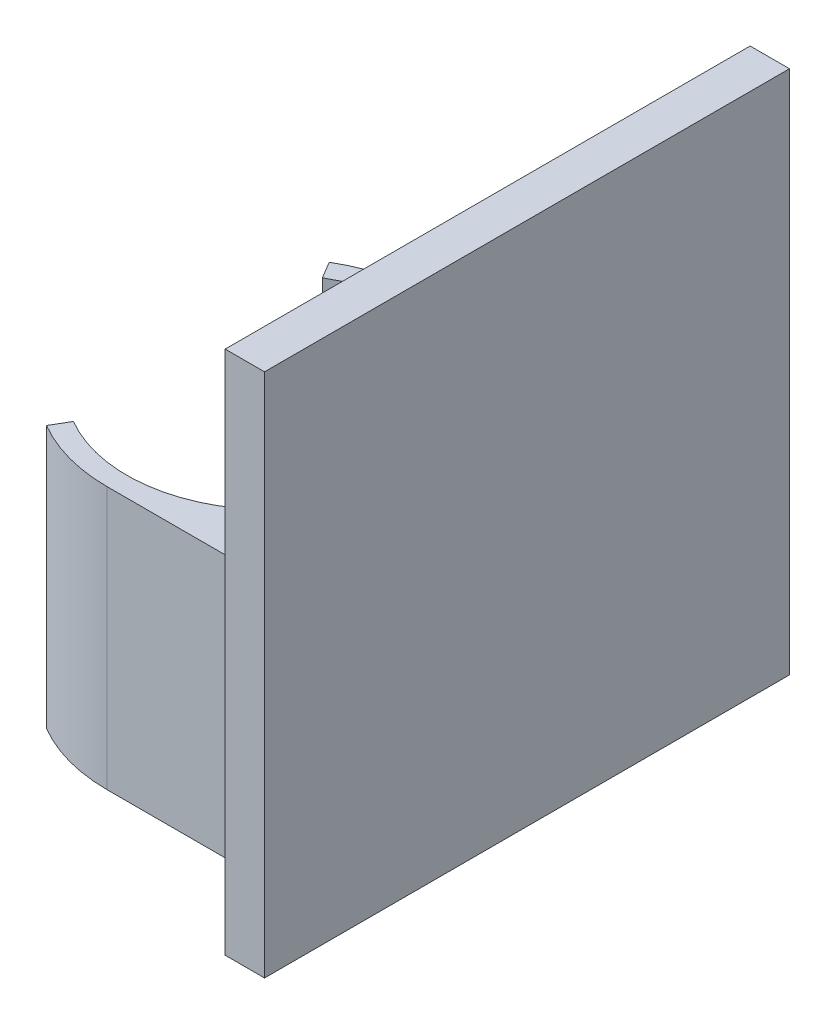
from build123d import *

# Parameters (mm, degrees)
SKETCH23_W          = 25
SKETCH23_H          = 25
BOSS_EXTRUDE6_DEPTH = 20
SKETCH24_R          = 11
CUT_EXTRUDE7_DEPTH  = 21
CUT_EXTRUDE8_DEPTH  = 21
SKETCH26_W          = 40
SKETCH26_H          = 40
BOSS_EXTRUDE7_DEPTH = 3


with BuildPart() as part:
    # Sketch23 → Boss-Extrude6 (new body)
    with BuildSketch(Plane(origin=(0, 0, 0), x_dir=(1, 0, 0), z_dir=(0, 1, 0))):
        Rectangle(SKETCH23_W, SKETCH23_H)
    extrude(amount=BOSS_EXTRUDE6_DEPTH)

    # Sketch24 → Cut-Extrude7 (cut, through all)
    with BuildSketch(Plane(origin=(0, 20, 0), x_dir=(1, 0, 0), z_dir=(0, 1, 0))):
        Circle(SKETCH24_R)
    extrude(amount=-CUT_EXTRUDE7_DEPTH, mode=Mode.SUBTRACT)

    # Sketch25 → Cut-Extrude8 (cut, through all)
    with BuildSketch(Plane(origin=(0, 20, 0), x_dir=(1, 0, 0), z_dir=(0, 1, 0))):
        with BuildLine():
            Line((0, 12.5), (-12.5, 12.5))
            Line((-12.5, 12.5), (-12.5, -12.5))
            Line((-12.5, -12.5), (0, -12.5))
            ThreePointArc((0, -12.5), (-3.28547543, -12.060499625), (-6.33991603, -10.772904192))
            Line((-6.33991603, -10.772904192), (-5.579126107, -9.480155689))
            ThreePointArc((-5.579126107, -9.480155689), (-11, 0), (-5.579126107, 9.480155689))
            Line((-5.579126107, 9.480155689), (-6.33991603, 10.772904192))
            ThreePointArc((-6.33991603, 10.772904192), (-3.28547543, 12.060499625), (0, 12.5))
        make_face()
    extrude(amount=-CUT_EXTRUDE8_DEPTH, mode=Mode.SUBTRACT)


with BuildPart() as body_2:
    # Sketch26 → Boss-Extrude7 (new body)
    with BuildSketch(Plane(origin=(16.5, 0, 0), x_dir=(0, 0, -1), z_dir=(1, 0, 0))):
        with Locations((0, 21.075080982)):
            Rectangle(SKETCH26_W, SKETCH26_H)
    extrude(amount=BOSS_EXTRUDE7_DEPTH)


solid = Compound([part.part, body_2.part])
